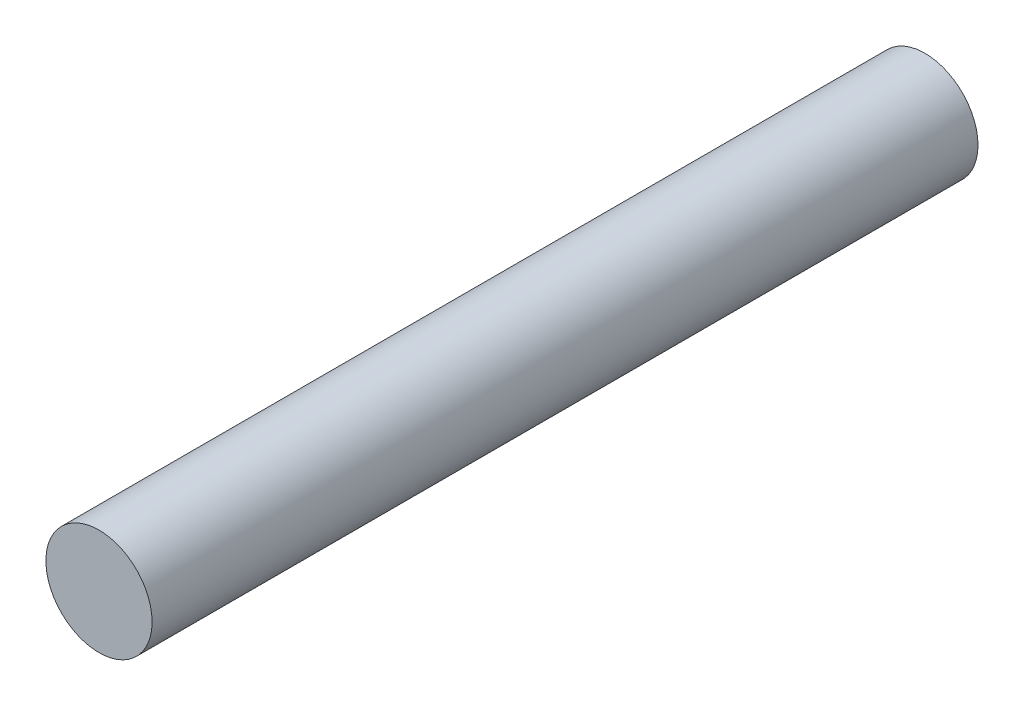
from build123d import *

# Parameters (mm, degrees)
CROQUIS1_R              = 9
SALIENTE_EXTRUIR1_DEPTH = 140


with BuildPart() as part:
    # Croquis1 → Saliente-Extruir1 (new body)
    with BuildSketch(Plane.XY):
        Circle(CROQUIS1_R)
    extrude(amount=SALIENTE_EXTRUIR1_DEPTH)


solid = part.part
